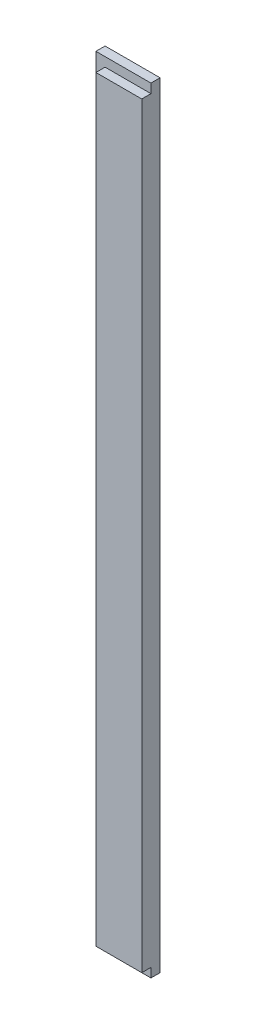
from build123d import *

# Parameters (mm, degrees)
SKETCH1_W           = 60
SKETCH1_H           = 845
BOSS_EXTRUDE1_DEPTH = 20
CUT_EXTRUDE1_DEPTH  = 10


with BuildPart() as part:
    # Sketch1 → Boss-Extrude1 (new body)
    with BuildSketch(Plane.XY):
        Rectangle(SKETCH1_W, SKETCH1_H)
    extrude(amount=BOSS_EXTRUDE1_DEPTH)

    # Sketch2 → Cut-Extrude1 (cut)
    with BuildSketch(Plane.XY.offset(20)):
        Polygon((30, 412.5), (-20, 412.5), (-20, -412.5), (30, -412.5), (30, -422.5), (-30, -422.5), (-30, 422.5), (30, 422.5), align=None)
    extrude(amount=-CUT_EXTRUDE1_DEPTH, mode=Mode.SUBTRACT)


solid = part.part
